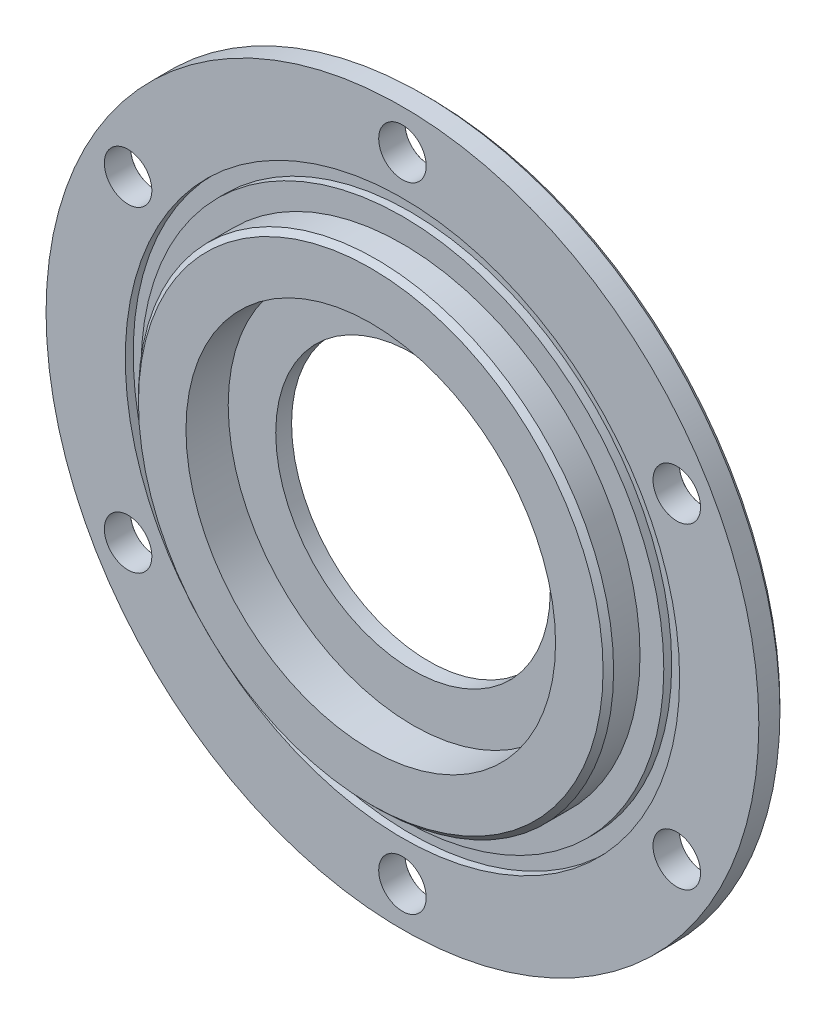
from build123d import *

# Parameters (mm, degrees)
SCHIZZO1_R                     = 67.5
ESTRUSIONE_ESTRUSIONE1_DEPTH   = 5
SCHIZZO2_R                     = 45
ESTRUSIONE_ESTRUSIONE2_DEPTH   = 6
SCHIZZO3_R                     = 35
TAGLIO_ESTRUSIONE1_DEPTH       = 8
SCHIZZO4_R                     = 26
TAGLIO_ESTRUSIONE2_DEPTH       = 4
SMUSSO1_SIZE                   = 1
FORO_PER_VITE_M8_1_D           = 9
FORO_PER_VITE_M8_1_CSINK_D     = 9.05
FORO_PER_VITE_M8_1_CSINK_ANGLE = 90
RIPETIZIONECIRCOLARE1_COUNT    = 6
SCHIZZO8_R                     = 52.5
SCHIZZO8_R_2                   = 49.5
TAGLIO_ESTRUSIONE3_DEPTH       = 1.5


with BuildPart() as part:
    # Schizzo1 → Estrusione-Estrusione1 (new body)
    with BuildSketch(Plane.XY):
        Circle(SCHIZZO1_R)
    extrude(amount=ESTRUSIONE_ESTRUSIONE1_DEPTH)

    # Schizzo2 → Estrusione-Estrusione2 (add)
    with BuildSketch(Plane.XY.offset(5)):
        Circle(SCHIZZO2_R)
    extrude(amount=ESTRUSIONE_ESTRUSIONE2_DEPTH)

    # Schizzo3 → Taglio-Estrusione1 (cut)
    with BuildSketch(Plane.XY.offset(11)):
        Circle(SCHIZZO3_R)
    extrude(amount=-TAGLIO_ESTRUSIONE1_DEPTH, mode=Mode.SUBTRACT)

    # Schizzo4 → Taglio-Estrusione2 (cut, through all)
    with BuildSketch(Plane.XY.offset(3)):
        Circle(SCHIZZO4_R)
    extrude(amount=-TAGLIO_ESTRUSIONE2_DEPTH, mode=Mode.SUBTRACT)

    # Smusso1
    smusso1_edges = [part.edges().sort_by_distance(p)[0] for p in [
        (-67.5, 0, 0),
        (-45, 0, 11),
    ]]
    chamfer(smusso1_edges, length=SMUSSO1_SIZE)

    # Foro per Vite M8-1 (through all)
    with Locations(Plane(origin=(0, 0, 0), x_dir=(-1, 0, 0), z_dir=(0, 0, -1))):
        with Locations((0, 60)):
            foro_per_vite_m8_1 = CounterSinkHole(FORO_PER_VITE_M8_1_D / 2, FORO_PER_VITE_M8_1_CSINK_D / 2, counter_sink_angle=FORO_PER_VITE_M8_1_CSINK_ANGLE)

    # RipetizioneCircolare1: Foro per Vite M8-1 ×6 about axis
    ripetizionecircolare1_axis = Axis((0, 0, 0), (0, 0, 1))
    for i in range(1, RIPETIZIONECIRCOLARE1_COUNT):
        add(foro_per_vite_m8_1.rotate(ripetizionecircolare1_axis, i * 360 / RIPETIZIONECIRCOLARE1_COUNT), mode=Mode.SUBTRACT)

    # Schizzo8 → Taglio-Estrusione3 (cut)
    with BuildSketch(Plane.XY.offset(5)):
        Circle(SCHIZZO8_R)
        Circle(SCHIZZO8_R_2, mode=Mode.SUBTRACT)
    extrude(amount=-TAGLIO_ESTRUSIONE3_DEPTH, mode=Mode.SUBTRACT)


solid = part.part
